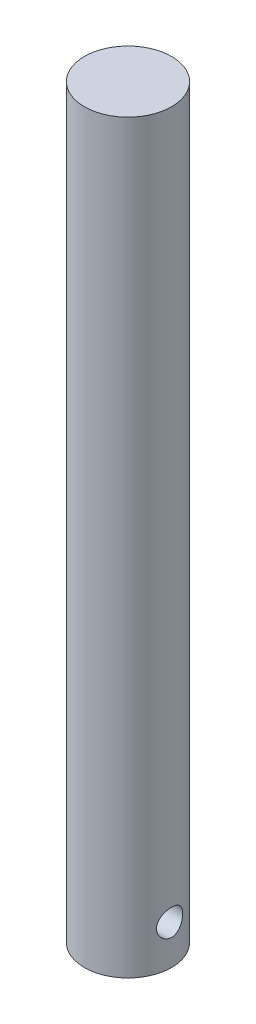
from build123d import *

# Parameters (mm, degrees)
CROQUIS1_R                   = 10
SALIENTE_EXTRUIR1_DEPTH      = 150
SALIENTE_EXTRUIR1_DEPTH_BACK = 21
CROQUIS2_R                   = 3
CORTAR_EXTRUIR1_DEPTH        = 12.5


with BuildPart() as part:
    # Croquis1 → Saliente-Extruir1 (new body, two sides)
    with BuildSketch(Plane(origin=(0, 0, 0), x_dir=(1, 0, 0), z_dir=(0, 1, 0))) as saliente_extruir1_sk:
        Circle(CROQUIS1_R)
    extrude(amount=SALIENTE_EXTRUIR1_DEPTH)
    extrude(saliente_extruir1_sk.sketch, amount=-SALIENTE_EXTRUIR1_DEPTH_BACK)

    # Croquis2 → Cortar-Extruir1 (cut, symmetric)
    with BuildSketch(Plane(origin=(0, 0, 0), x_dir=(0, 0, -1), z_dir=(1, 0, 0))):
        with Locations((0, -12)):
            Circle(CROQUIS2_R)
    extrude(amount=CORTAR_EXTRUIR1_DEPTH, both=True, mode=Mode.SUBTRACT)


solid = part.part
